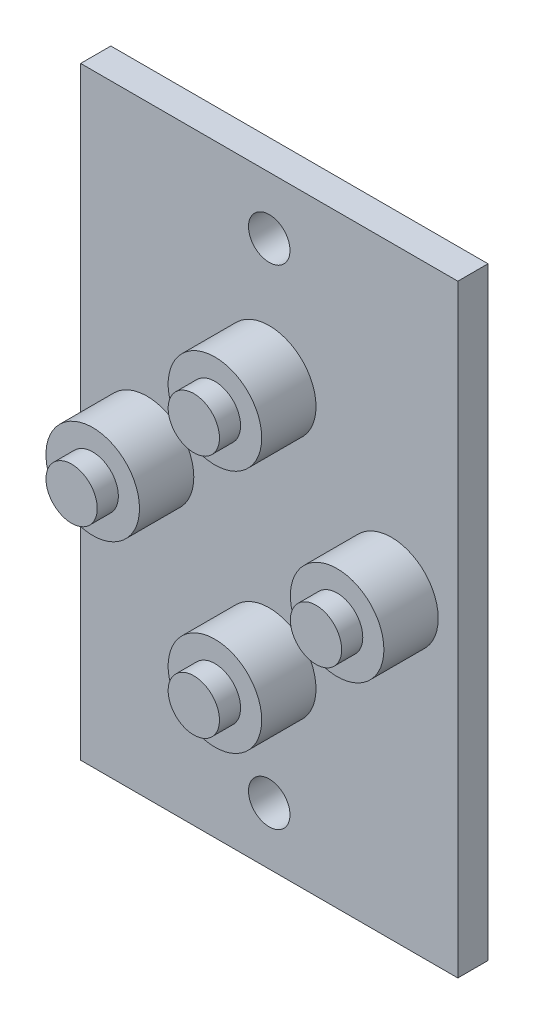
from build123d import *

# Parameters (mm, degrees)
SKETCH1_W           = 25
SKETCH1_H           = 40
BOSS_EXTRUDE1_DEPTH = 2
SKETCH2_R           = 3.1
BOSS_EXTRUDE2_DEPTH = 3.6
SKETCH3_R           = 1.7
BOSS_EXTRUDE3_DEPTH = 1.4
SKETCH4_R           = 1.7
BOSS_EXTRUDE4_DEPTH = 1.4
SKETCH5_R           = 1.7
BOSS_EXTRUDE5_DEPTH = 1.4
SKETCH6_R           = 1.7
BOSS_EXTRUDE6_DEPTH = 1.4
SKETCH7_R           = 1.375
CUT_EXTRUDE1_DEPTH  = 3


with BuildPart() as part:
    # Sketch1 → Boss-Extrude1 (new body)
    with BuildSketch(Plane.XY):
        Rectangle(SKETCH1_W, SKETCH1_H)
    extrude(amount=BOSS_EXTRUDE1_DEPTH)

    # Sketch2 → Boss-Extrude2 (add)
    with BuildSketch(Plane.XY.offset(2)):
        with Locations((-8.1, 0)):
            Circle(SKETCH2_R)
        with Locations((8.1, 0)):
            Circle(SKETCH2_R)
        with Locations((0, 8.1)):
            Circle(SKETCH2_R)
        with Locations((0, -8.1)):
            Circle(SKETCH2_R)
    extrude(amount=BOSS_EXTRUDE2_DEPTH)

    # Sketch3 → Boss-Extrude3 (add)
    with BuildSketch(Plane.XY.offset(5.6)):
        with Locations((0, 8.1)):
            Circle(SKETCH3_R)
    extrude(amount=BOSS_EXTRUDE3_DEPTH)

    # Sketch4 → Boss-Extrude4 (add)
    with BuildSketch(Plane.XY.offset(5.6)):
        with Locations((-8.1, 0)):
            Circle(SKETCH4_R)
    extrude(amount=BOSS_EXTRUDE4_DEPTH)

    # Sketch5 → Boss-Extrude5 (add)
    with BuildSketch(Plane.XY.offset(5.6)):
        with Locations((8.1, 0)):
            Circle(SKETCH5_R)
    extrude(amount=BOSS_EXTRUDE5_DEPTH)

    # Sketch6 → Boss-Extrude6 (add)
    with BuildSketch(Plane.XY.offset(5.6)):
        with Locations((0, -8.1)):
            Circle(SKETCH6_R)
    extrude(amount=BOSS_EXTRUDE6_DEPTH)

    # Sketch7 → Cut-Extrude1 (cut)
    with BuildSketch(Plane.XY.offset(2)):
        with Locations((0, 16.2)):
            Circle(SKETCH7_R)
        with Locations((0, -16.2)):
            Circle(SKETCH7_R)
    extrude(amount=-CUT_EXTRUDE1_DEPTH, mode=Mode.SUBTRACT)


solid = part.part
